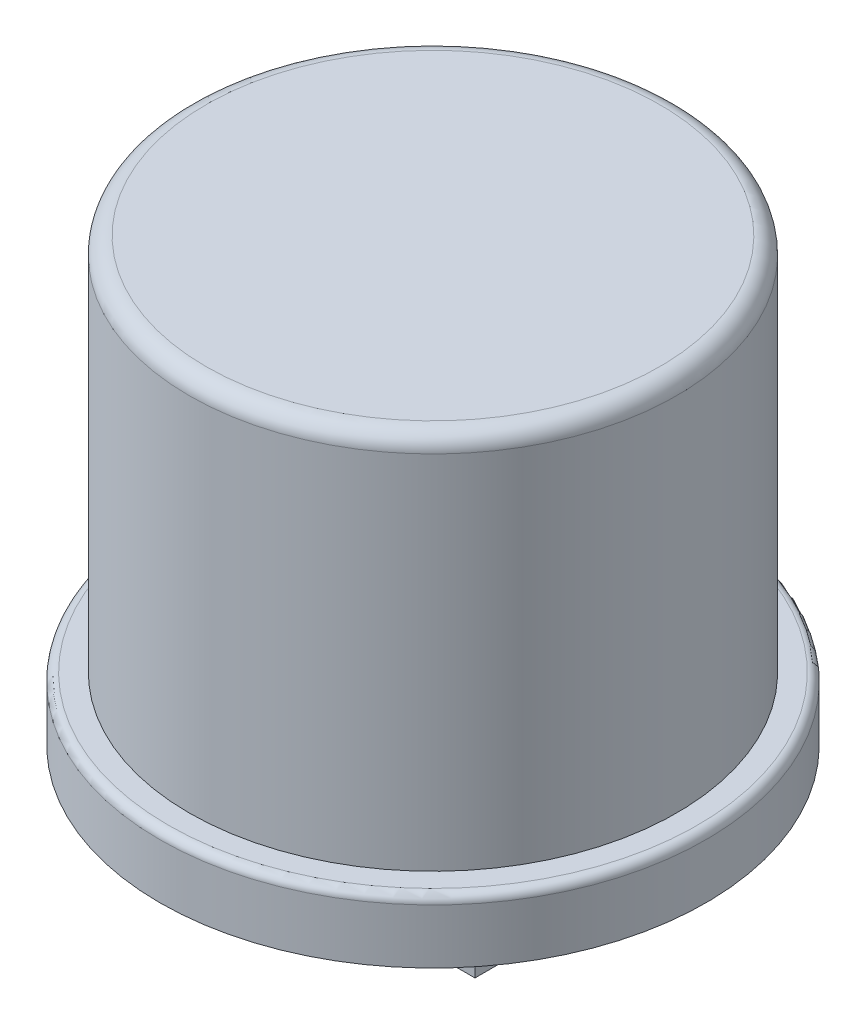
from build123d import *

# Parameters (mm, degrees)
SKETCH1_R           = 6.5
BOSS_EXTRUDE1_DEPTH = 1.5
SKETCH2_R           = 5.8
BOSS_EXTRUDE2_DEPTH = 9
FILLET1_R           = 0.4
SKETCH3_R           = 5
CUT_EXTRUDE1_DEPTH  = 4.8
BOSS_EXTRUDE3_DEPTH = 4.8
SKETCH5_W           = 2
SKETCH5_H           = 0.8
SKETCH5_W_2         = 1
SKETCH5_H_2         = 3.8
BOSS_EXTRUDE4_DEPTH = 7.2
CUT_EXTRUDE2_REACH  = 10.4
BOSS_EXTRUDE5_DEPTH = 3.8
FILLET2_R           = 0.1
FILLET3_R           = 0.2


with BuildPart() as part:
    # Sketch1 → Boss-Extrude1 (new body)
    with BuildSketch(Plane(origin=(0, 0, 0), x_dir=(1, 0, 0), z_dir=(0, 1, 0))):
        Circle(SKETCH1_R)
    extrude(amount=BOSS_EXTRUDE1_DEPTH)

    # Sketch2 → Boss-Extrude2 (add)
    with BuildSketch(Plane(origin=(0, 1.5, 0), x_dir=(1, 0, 0), z_dir=(0, 1, 0))):
        Circle(SKETCH2_R)
    extrude(amount=BOSS_EXTRUDE2_DEPTH)

    # Fillet1
    fillet1_edges = [part.edges().sort_by_distance(p)[0] for p in [
        (-5.8, 10.5, 0),
    ]]
    fillet(fillet1_edges, radius=FILLET1_R)

    # Sketch3 → Cut-Extrude1 (cut)
    with BuildSketch(Plane.XZ):
        Circle(SKETCH3_R)
    extrude(amount=-CUT_EXTRUDE1_DEPTH, mode=Mode.SUBTRACT)

    # Sketch4 → Boss-Extrude3 (add)
    with BuildSketch(Plane.XZ.offset(-4.8)):
        with BuildLine():
            Line((-4.990991885, 0.3), (-2.9, 0.3))
            Line((-2.9, 0.3), (-2.9, -0.3))
            Line((-2.9, -0.3), (-4.990991885, -0.3))
            ThreePointArc((-4.990991885, -0.3), (-5, 0), (-4.990991885, 0.3))
        make_face()
        with BuildLine():
            Line((2.9, 0.3), (2.9, -0.3))
            Line((2.9, -0.3), (4.990991885, -0.3))
            ThreePointArc((4.990991885, -0.3), (5, 0), (4.990991885, 0.3))
            Line((4.990991885, 0.3), (2.9, 0.3))
        make_face()
        with BuildLine():
            Line((-0.3, 4.990991885), (-0.3, 2.7))
            Line((-0.3, 2.7), (0.3, 2.7))
            Line((0.3, 2.7), (0.3, 4.990991885))
            ThreePointArc((0.3, 4.990991885), (0, 5), (-0.3, 4.990991885))
        make_face()
        with BuildLine():
            Line((0.3, -2.7), (-0.3, -2.7))
            Line((-0.3, -2.7), (-0.3, -4.990991885))
            ThreePointArc((-0.3, -4.990991885), (0, -5), (0.3, -4.990991885))
            Line((0.3, -4.990991885), (0.3, -2.7))
        make_face()
    extrude(amount=BOSS_EXTRUDE3_DEPTH)

    # Sketch5 → Boss-Extrude4 (add)
    with BuildSketch(Plane.XZ.offset(-4.8)):
        with Locations((0, 2.3)):
            Rectangle(SKETCH5_W, SKETCH5_H)
        with Locations((-2.4, 0)):
            Rectangle(SKETCH5_W_2, SKETCH5_H_2)
        with Locations((2.4, 0)):
            Rectangle(SKETCH5_W_2, SKETCH5_H_2)
        with Locations((0, -2.3)):
            Rectangle(SKETCH5_W, SKETCH5_H)
    extrude(amount=BOSS_EXTRUDE4_DEPTH)

    # Sketch6 → Cut-Extrude2 (cut, up to next)
    with BuildSketch(Plane.XY.offset(1.9), mode=Mode.PRIVATE) as cut_extrude2_sk1:
        Polygon((-1.9, -2.4), (-1.9, -1.9625), (-2.4, -2.4), align=None)
    cut_extrude2_tool1 = extrude(cut_extrude2_sk1.sketch, amount=-CUT_EXTRUDE2_REACH, mode=Mode.PRIVATE) & part.part
    add(cut_extrude2_tool1.solids().sort_by_distance((-2.066667, -2.254167, 1.9))[0], mode=Mode.SUBTRACT)
    # Sketch6 → Cut-Extrude2 (cut, up to next)
    with BuildSketch(Plane.XY.offset(1.9), mode=Mode.PRIVATE) as cut_extrude2_sk2:
        Polygon((1.9, -1.9625), (1.9, -2.4), (2.4, -2.4), align=None)
    cut_extrude2_tool2 = extrude(cut_extrude2_sk2.sketch, amount=-CUT_EXTRUDE2_REACH, mode=Mode.PRIVATE) & part.part
    add(cut_extrude2_tool2.solids().sort_by_distance((2.066667, -2.254167, 1.9))[0], mode=Mode.SUBTRACT)

    # Sketch6_3 → Boss-Extrude5 (add)
    with BuildSketch(Plane.XY.offset(1.9)):
        Polygon((-1.6, -1.7), (-1.9, -1.4), (-1.9, -1.9625), align=None)
        Polygon((1.6, -1.7), (1.9, -1.9625), (1.9, -1.4), align=None)
    extrude(amount=-BOSS_EXTRUDE5_DEPTH)

    # Fillet2
    fillet2_edges = [part.edges().sort_by_distance(p)[0] for p in [
        (-1.6, -1.7, 0),
        (1.6, -1.7, 0),
    ]]
    fillet(fillet2_edges, radius=FILLET2_R)

    # Fillet3
    fillet3_edges = [part.edges().sort_by_distance(p)[0] for p in [
        (-6.5, 1.5, 0),
    ]]
    fillet(fillet3_edges, radius=FILLET3_R)


solid = part.part
